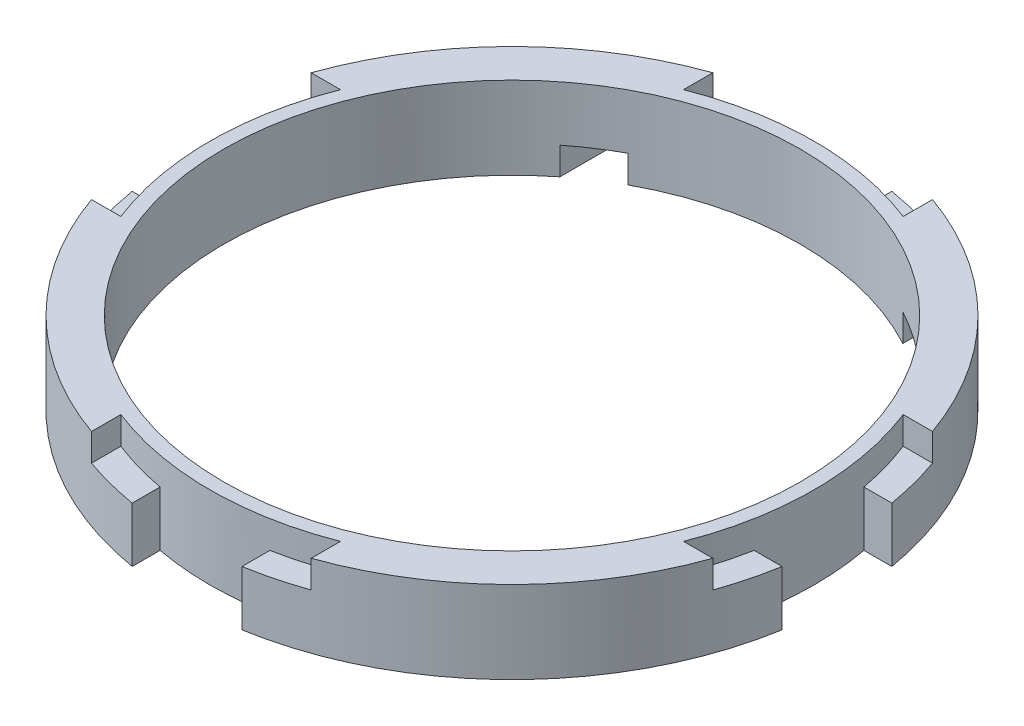
from build123d import *

# Parameters (mm, degrees)
SKETCH1_R           = 12
SKETCH1_R_2         = 10.5
BOSS_EXTRUDE1_DEPTH = 3
CUT_EXTRUDE1_DEPTH  = 1
CUT_EXTRUDE2_DEPTH  = 3
CUT_EXTRUDE3_DEPTH  = 1


with BuildPart() as part:
    # Sketch1 → Boss-Extrude1 (new body)
    with BuildSketch(Plane(origin=(0, 0, 0), x_dir=(1, 0, 0), z_dir=(0, 1, 0))):
        Circle(SKETCH1_R)
        Circle(SKETCH1_R_2, mode=Mode.SUBTRACT)
    extrude(amount=-BOSS_EXTRUDE1_DEPTH)

    # Sketch6 → Cut-Extrude1 (cut)
    with BuildSketch(Plane(origin=(0, 0, 0), x_dir=(1, 0, 0), z_dir=(0, 1, 0))):
        with BuildLine():
            Line((10.246950766, 4), (11.313708499, 4))
            ThreePointArc((11.313708499, 4), (12, 0), (11.313708499, -4))
            Line((11.313708499, -4), (10.246950766, -4))
            ThreePointArc((10.246950766, -4), (11, 0), (10.246950766, 4))
        make_face()
        with BuildLine():
            Line((-4, 10.246950766), (-4, 11.313708499))
            ThreePointArc((-4, 11.313708499), (0, 12), (4, 11.313708499))
            Line((4, 11.313708499), (4, 10.246950766))
            ThreePointArc((4, 10.246950766), (0, 11), (-4, 10.246950766))
        make_face()
        with BuildLine():
            Line((4, -10.246950766), (4, -11.313708499))
            ThreePointArc((4, -11.313708499), (0, -12), (-4, -11.313708499))
            Line((-4, -11.313708499), (-4, -10.246950766))
            ThreePointArc((-4, -10.246950766), (0, -11), (4, -10.246950766))
        make_face()
        with BuildLine():
            Line((-10.246950766, -4), (-11.313708499, -4))
            ThreePointArc((-11.313708499, -4), (-12, 0), (-11.313708499, 4))
            Line((-11.313708499, 4), (-10.246950766, 4))
            ThreePointArc((-10.246950766, 4), (-11, 0), (-10.246950766, -4))
        make_face()
    extrude(amount=-CUT_EXTRUDE1_DEPTH, mode=Mode.SUBTRACT)

    # Sketch7 → Cut-Extrude2 (cut, through all)
    with BuildSketch(Plane(origin=(0, -1, 0), x_dir=(1, 0, 0), z_dir=(0, 1, 0))):
        with BuildLine():
            Line((-2, 10.816653826), (-2, 11.832159566))
            ThreePointArc((-2, 11.832159566), (0, 12), (2, 11.832159566))
            Line((2, 11.832159566), (2, 10.816653826))
            ThreePointArc((2, 10.816653826), (0, 11), (-2, 10.816653826))
        make_face()
        with BuildLine():
            Line((10.816653826, -2), (11.832159566, -2))
            ThreePointArc((11.832159566, -2), (12, 0), (11.832159566, 2))
            Line((11.832159566, 2), (10.816653826, 2))
            ThreePointArc((10.816653826, 2), (11, 0), (10.816653826, -2))
        make_face()
        with BuildLine():
            Line((-2, -10.816653826), (-2, -11.832159566))
            ThreePointArc((-2, -11.832159566), (0, -12), (2, -11.832159566))
            Line((2, -11.832159566), (2, -10.816653826))
            ThreePointArc((2, -10.816653826), (0, -11), (-2, -10.816653826))
        make_face()
        with BuildLine():
            Line((-10.816653826, 2), (-11.832159566, 2))
            ThreePointArc((-11.832159566, 2), (-12, 0), (-11.832159566, -2))
            Line((-11.832159566, -2), (-10.816653826, -2))
            ThreePointArc((-10.816653826, -2), (-11, 0), (-10.816653826, 2))
        make_face()
    extrude(amount=-CUT_EXTRUDE2_DEPTH, mode=Mode.SUBTRACT)

    # Sketch8 → Cut-Extrude3 (cut)
    with BuildSketch(Plane.XZ.offset(3)):
        with BuildLine():
            Line((-5, -9.233092656), (-5, -10.908712115))
            ThreePointArc((-5, -10.908712115), (-5.764655514, -10.52467324), (-6.5, -10.087120501))
            Line((-6.5, -10.087120501), (-6.5, -8.246211251))
            ThreePointArc((-6.5, -8.246211251), (-5.77113366, -8.771773838), (-5, -9.233092656))
        make_face()
        with BuildLine():
            Line((5, -9.233092656), (5, -10.908712115))
            ThreePointArc((5, -10.908712115), (5.764655514, -10.52467324), (6.5, -10.087120501))
            Line((6.5, -10.087120501), (6.5, -8.246211251))
            ThreePointArc((6.5, -8.246211251), (5.77113366, -8.771773838), (5, -9.233092656))
        make_face()
    extrude(amount=-CUT_EXTRUDE3_DEPTH, mode=Mode.SUBTRACT)


solid = part.part
